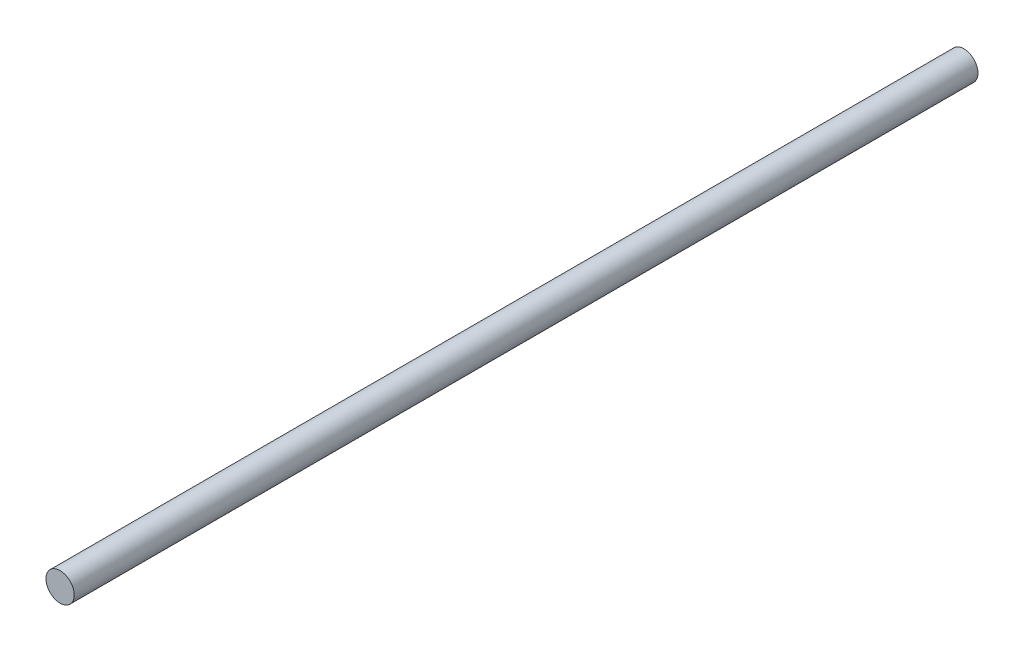
from build123d import *

# Parameters (mm, degrees)
SKETCH1_R           = 1.5
BOSS_EXTRUDE1_DEPTH = 96


with BuildPart() as part:
    # Sketch1 → Boss-Extrude1 (new body)
    with BuildSketch(Plane.XY):
        Circle(SKETCH1_R)
    extrude(amount=BOSS_EXTRUDE1_DEPTH)


solid = part.part
